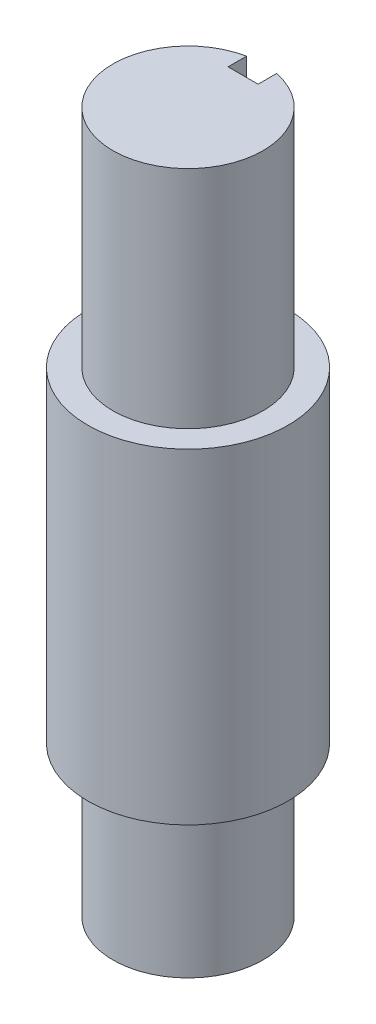
from build123d import *

# Parameters (mm, degrees)
SKETCH1_R           = 20
BOSS_EXTRUDE1_DEPTH = 40
SKETCH2_R           = 15
BOSS_EXTRUDE2_DEPTH = 30
SKETCH3_R           = 15
BOSS_EXTRUDE3_DEPTH = 30
SKETCH4_R           = 20
SKETCH4_R_2         = 15
CUT_EXTRUDE1_DEPTH  = 15
SKETCH5_W           = 6
SKETCH5_H           = 8
CUT_EXTRUDE2_DEPTH  = 45


with BuildPart() as part:
    # Sketch1 → Boss-Extrude1 (new body, symmetric)
    with BuildSketch(Plane(origin=(0, 0, 0), x_dir=(1, 0, 0), z_dir=(0, 1, 0))):
        Circle(SKETCH1_R)
    extrude(amount=BOSS_EXTRUDE1_DEPTH, both=True)

    # Sketch2 → Boss-Extrude2 (add)
    with BuildSketch(Plane(origin=(0, 40, 0), x_dir=(1, 0, 0), z_dir=(0, 1, 0))):
        Circle(SKETCH2_R)
    extrude(amount=BOSS_EXTRUDE2_DEPTH)

    # Sketch3 → Boss-Extrude3 (add)
    with BuildSketch(Plane.XZ.offset(40)):
        Circle(SKETCH3_R)
    extrude(amount=BOSS_EXTRUDE3_DEPTH)

    # Sketch4 → Cut-Extrude1 (cut)
    with BuildSketch(Plane(origin=(0, 40, 0), x_dir=(1, 0, 0), z_dir=(0, 1, 0))):
        Circle(SKETCH4_R)
        Circle(SKETCH4_R_2, mode=Mode.SUBTRACT)
    extrude(amount=-CUT_EXTRUDE1_DEPTH, mode=Mode.SUBTRACT)

    # Sketch5 → Cut-Extrude2 (cut)
    with BuildSketch(Plane(origin=(0, 70, 0), x_dir=(1, 0, 0), z_dir=(0, 1, 0))):
        with Locations((0, 15)):
            Rectangle(SKETCH5_W, SKETCH5_H)
    extrude(amount=-CUT_EXTRUDE2_DEPTH, mode=Mode.SUBTRACT)


solid = part.part
